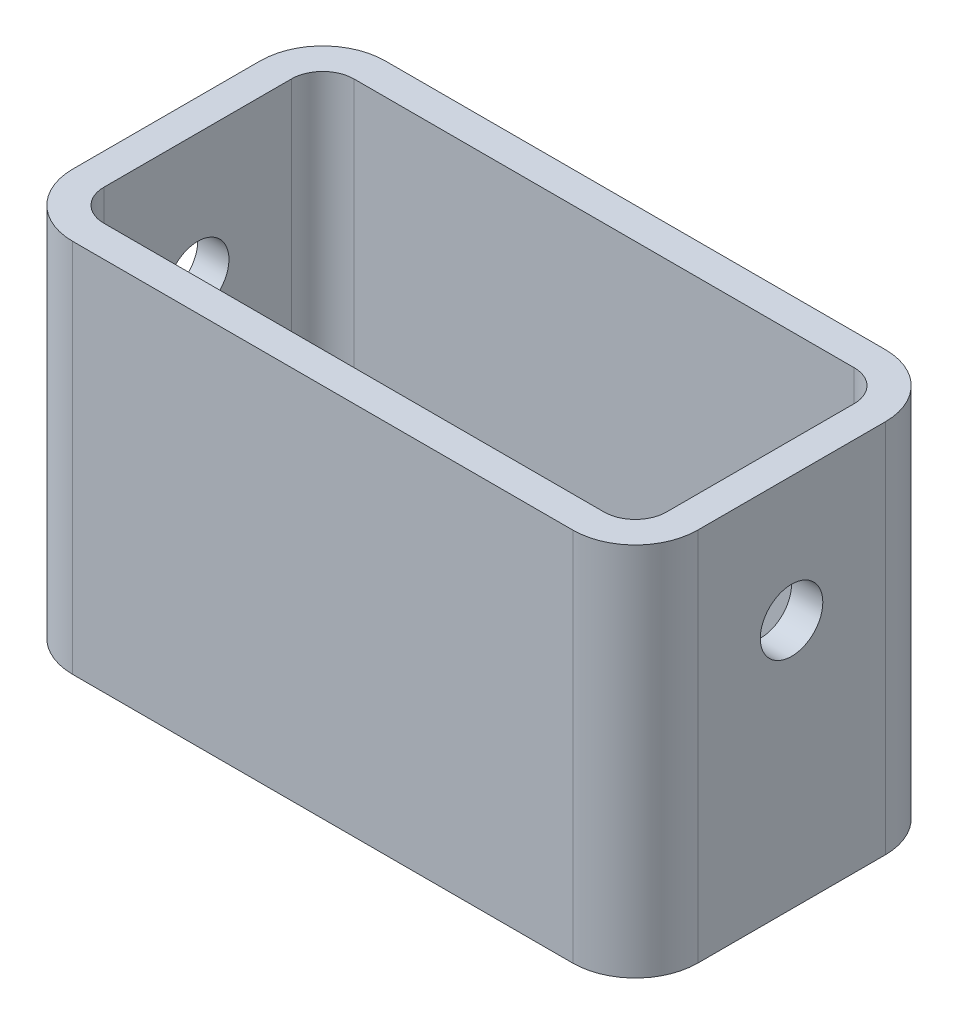
from build123d import *

# Parameters (mm, degrees)
SKETCH1_W           = 100
SKETCH1_H           = 60
BOSS_EXTRUDE1_DEPTH = 50
FILLET1_R           = 10
SHELL1_T            = -5
SKETCH3_R           = 5
CUT_EXTRUDE1_DEPTH  = 101


with BuildPart() as part:
    # Sketch1 → Boss-Extrude1 (new body)
    with BuildSketch(Plane.XY):
        with Locations((-84.464065936, -92.64803072)):
            Rectangle(SKETCH1_W, SKETCH1_H)
    extrude(amount=BOSS_EXTRUDE1_DEPTH)

    # Fillet1
    fillet1_edges = [part.edges().sort_by_distance(p)[0] for p in [
        (-34.464065936, -92.64803072, 50),
        (-134.464065936, -92.64803072, 50),
        (-34.464065936, -92.64803072, 0),
        (-134.464065936, -92.64803072, 0),
    ]]
    fillet(fillet1_edges, radius=FILLET1_R)

    # Shell1
    shell1_openings = [part.faces().sort_by_distance(p)[0] for p in [
        (-84.464065936, -62.64803072, 25),
    ]]
    offset(amount=SHELL1_T, openings=shell1_openings, kind=Kind.INTERSECTION)

    # Sketch3 → Cut-Extrude1 (cut, through all)
    with BuildSketch(Plane(origin=(-34.464065936, 0, 0), x_dir=(0, 0, -1), z_dir=(1, 0, 0))):
        with Locations((-25, -82.64803072)):
            Circle(SKETCH3_R)
    extrude(amount=-CUT_EXTRUDE1_DEPTH, mode=Mode.SUBTRACT)


solid = part.part
